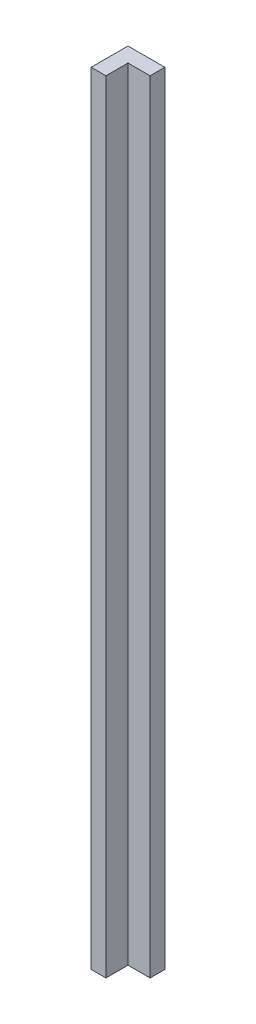
from build123d import *

# Parameters (mm, degrees)
BOSS_EXTRUDE1_DEPTH = 106


with BuildPart() as part:
    # Sketch1 → Boss-Extrude1 (new body)
    with BuildSketch(Plane(origin=(0, 0, 0), x_dir=(1, 0, 0), z_dir=(0, 1, 0))):
        Polygon((-1.592849237, 1.703201648), (2.13849988, 1.703201648), (2.13849988, -0.296798352), (-0.86150012, -0.296798352), (-0.86150012, -3.296798352), (-2.86150012, -3.296798352), (-2.86150012, 1.703201648), align=None)
    extrude(amount=BOSS_EXTRUDE1_DEPTH)


solid = part.part
